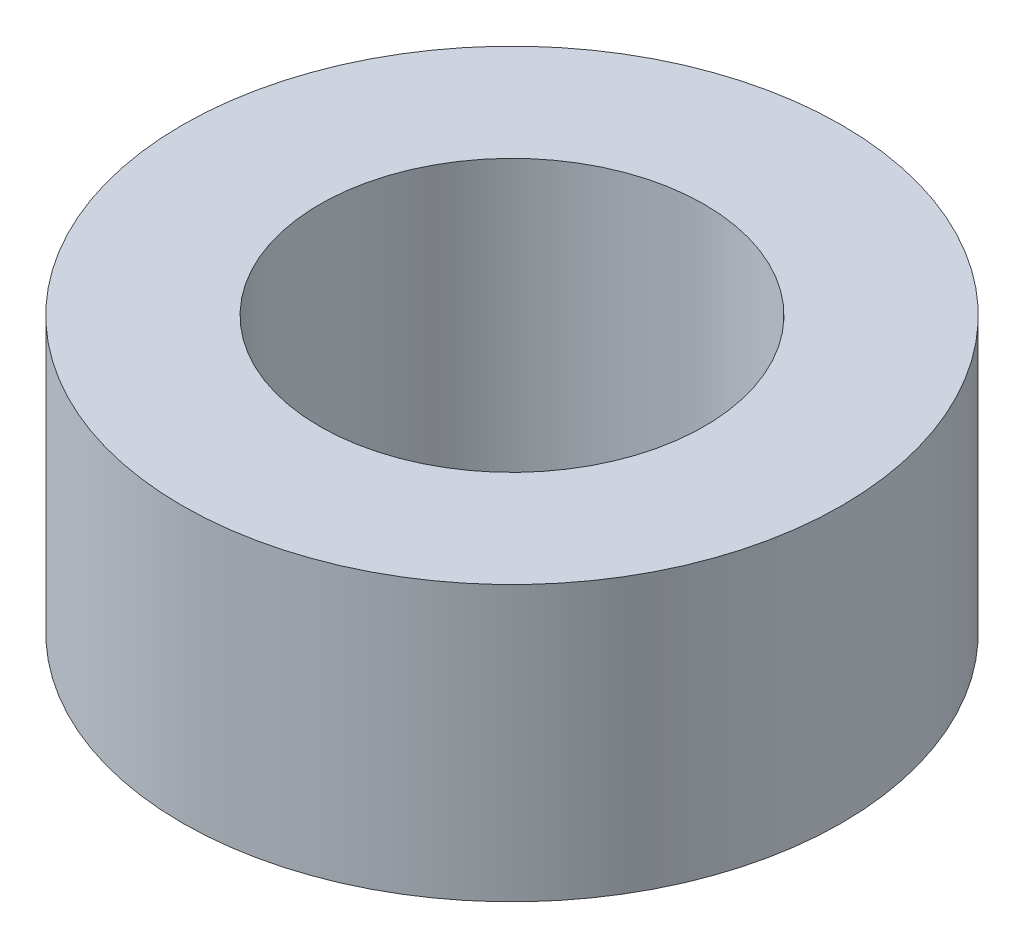
from build123d import *

# Parameters (mm, degrees)
SKETCH1_R           = 12
SKETCH1_R_2         = 7
BOSS_EXTRUDE1_DEPTH = 10


with BuildPart() as part:
    # Sketch1 → Boss-Extrude1 (new body)
    with BuildSketch(Plane(origin=(0, 0, 0), x_dir=(1, 0, 0), z_dir=(0, 1, 0))):
        Circle(SKETCH1_R)
        Circle(SKETCH1_R_2, mode=Mode.SUBTRACT)
    extrude(amount=BOSS_EXTRUDE1_DEPTH)


solid = part.part
